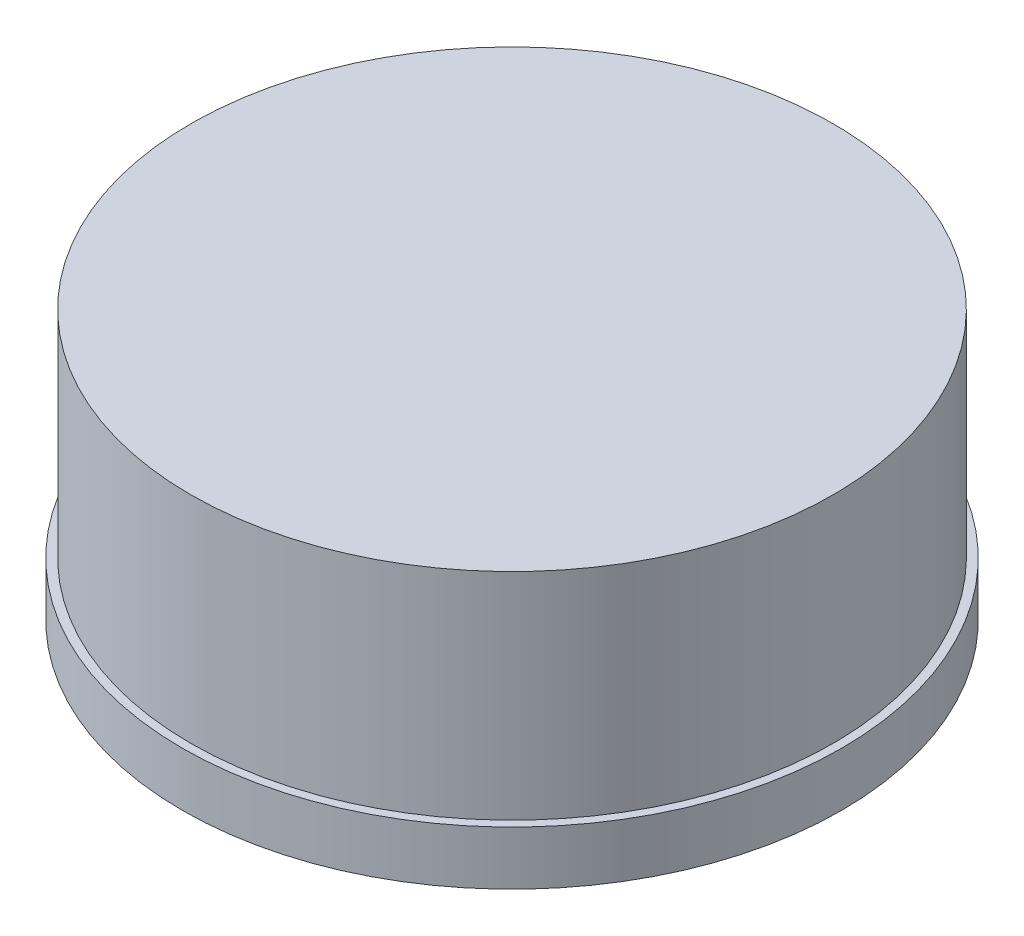
from build123d import *

# Parameters (mm, degrees)
SKETCH1_R           = 4.9
BOSS_EXTRUDE1_DEPTH = 0.8
SKETCH2_R           = 4.775
BOSS_EXTRUDE2_DEPTH = 3.2
SKETCH3_R           = 4.05
CUT_EXTRUDE1_DEPTH  = 3.2


with BuildPart() as part:
    # Sketch1 → Boss-Extrude1 (new body)
    with BuildSketch(Plane(origin=(0, 0, 0), x_dir=(1, 0, 0), z_dir=(0, 1, 0))):
        Circle(SKETCH1_R)
    extrude(amount=BOSS_EXTRUDE1_DEPTH)

    # Sketch2 → Boss-Extrude2 (add)
    with BuildSketch(Plane(origin=(0, 0.8, 0), x_dir=(1, 0, 0), z_dir=(0, 1, 0))):
        Circle(SKETCH2_R)
    extrude(amount=BOSS_EXTRUDE2_DEPTH)

    # Sketch3 → Cut-Extrude1 (cut)
    with BuildSketch(Plane(origin=(0, 0, 0), x_dir=(-1, 0, 0), z_dir=(0, -1, 0))):
        Circle(SKETCH3_R)
    extrude(amount=-CUT_EXTRUDE1_DEPTH, mode=Mode.SUBTRACT)


solid = part.part
